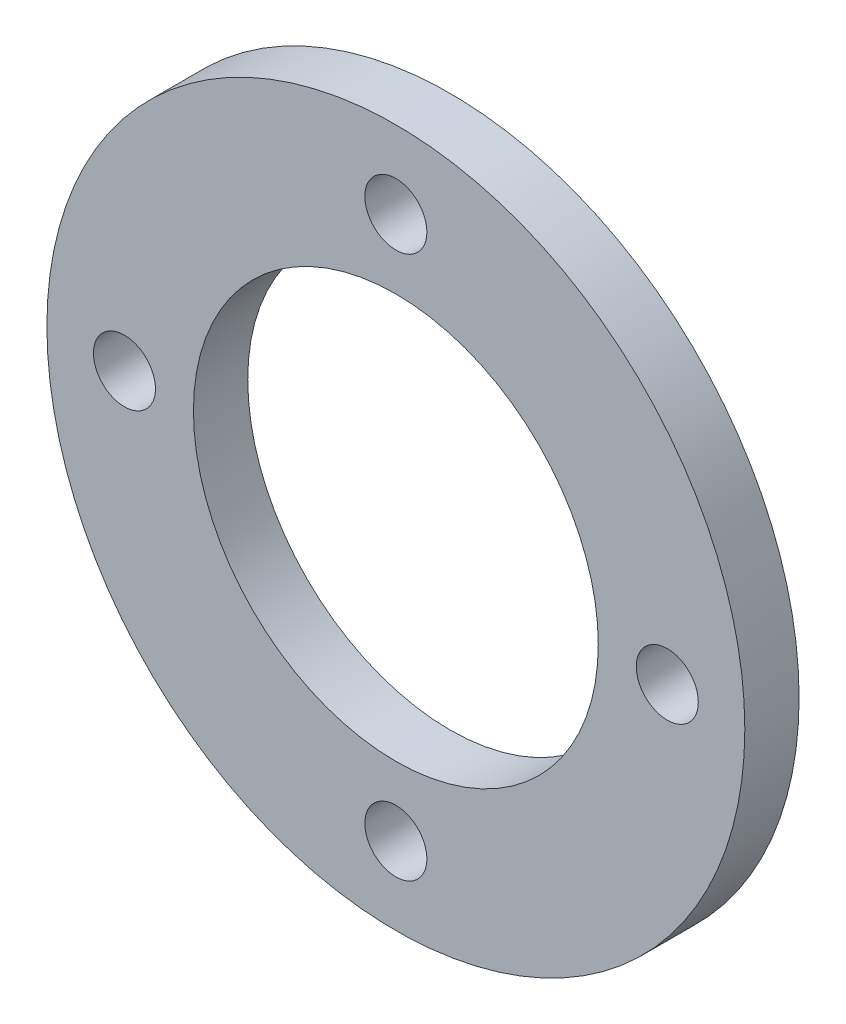
from build123d import *

# Parameters (mm, degrees)
CROQUIS1_R              = 45
SALIENTE_EXTRUIR1_DEPTH = 7
CROQUIS2_R              = 26.1
CORTAR_EXTRUIR1_DEPTH   = 8
CROQUIS3_R              = 4
CORTAR_EXTRUIR2_DEPTH   = 8


with BuildPart() as part:
    # Croquis1 → Saliente-Extruir1 (new body)
    with BuildSketch(Plane.XY):
        Circle(CROQUIS1_R)
    extrude(amount=SALIENTE_EXTRUIR1_DEPTH)

    # Croquis2 → Cortar-Extruir1 (cut, through all)
    with BuildSketch(Plane.XY.offset(7)):
        Circle(CROQUIS2_R)
    extrude(amount=-CORTAR_EXTRUIR1_DEPTH, mode=Mode.SUBTRACT)

    # Croquis3 → Cortar-Extruir2 (cut, through all)
    with BuildSketch(Plane.XY.offset(7)):
        with Locations((0, 35)):
            Circle(CROQUIS3_R)
        with Locations((35, 0)):
            Circle(CROQUIS3_R)
        with Locations((0, -35)):
            Circle(CROQUIS3_R)
        with Locations((-35, 0)):
            Circle(CROQUIS3_R)
    extrude(amount=-CORTAR_EXTRUIR2_DEPTH, mode=Mode.SUBTRACT)


solid = part.part
